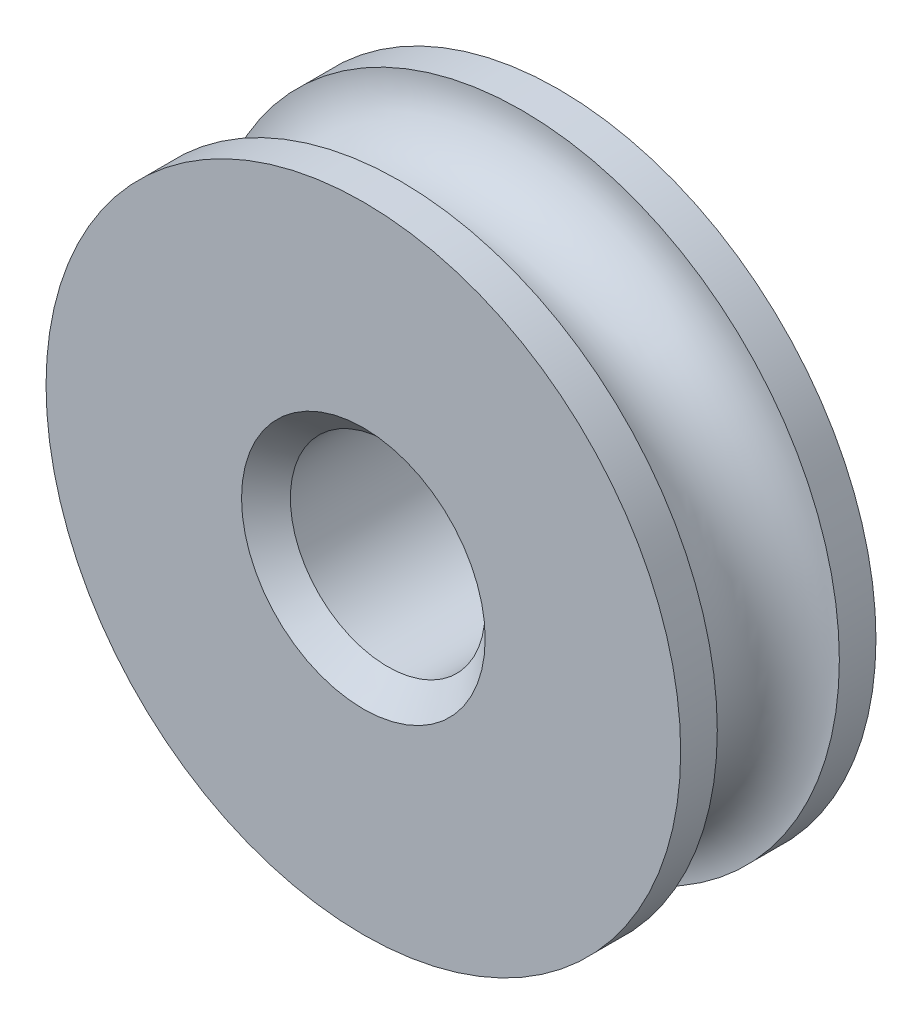
from build123d import *

# Parameters (mm, degrees)
CHAFL_N2_SIZE = 0.5


with BuildPart() as part:
    # Croquis1 → Revolución1 (revolve)
    with BuildSketch(Plane(origin=(0, -190, 0), x_dir=(1, 0, 0), z_dir=(0, 1, 0))):
        with BuildLine():
            Line((6.5, 0), (6.5, 0.75))
            ThreePointArc((6.5, 0.75), (5.25, 2), (6.5, 3.25))
            Line((6.5, 3.25), (6.5, 4))
            Line((6.5, 4), (1.995632004, 4))
            Line((1.995632004, 4), (1.995632004, 0))
            Line((1.995632004, 0), (6.5, 0))
        make_face()
    revolve(axis=Axis((0, -190, -5), (0, 0, 1)))

    # Chaflán2
    chafl_n2_edges = [part.edges().sort_by_distance(p)[0] for p in [
        (-1.995632004, -190, 0),
        (-1.995632004, -190, -4),
    ]]
    chamfer(chafl_n2_edges, length=CHAFL_N2_SIZE)


solid = part.part
